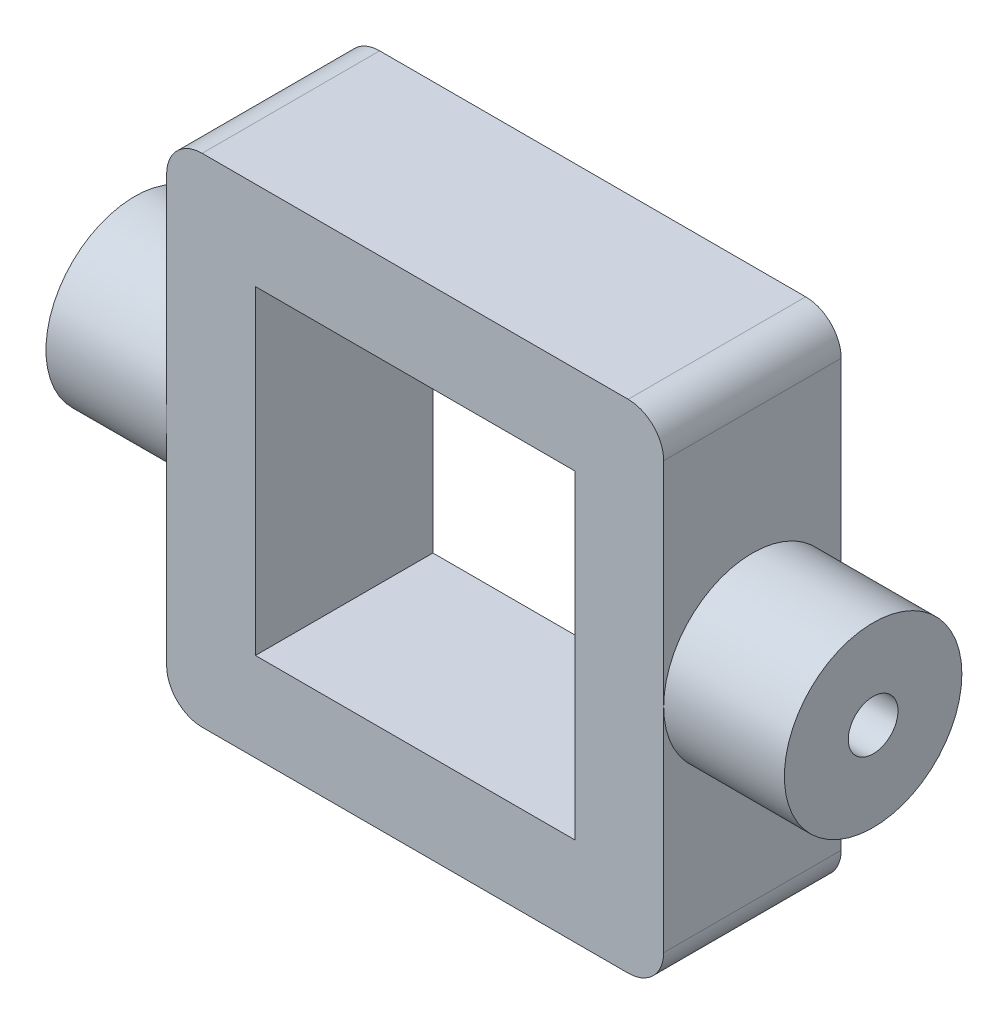
from build123d import *

# Parameters (mm, degrees)
SKETCH1_W           = 14
SKETCH1_H           = 14
SKETCH1_W_2         = 9
SKETCH1_H_2         = 9
BOSS_EXTRUDE1_DEPTH = 2.5
SKETCH3_R           = 2.5
BOSS_EXTRUDE2_DEPTH = 3.4
SKETCH4_R           = 0.7
CUT_EXTRUDE1_DEPTH  = 5
FILLET1_R           = 1


with BuildPart() as part:
    # Sketch1 → Boss-Extrude1 (new body, symmetric)
    with BuildSketch(Plane.XY):
        Rectangle(SKETCH1_W, SKETCH1_H)
        Rectangle(SKETCH1_W_2, SKETCH1_H_2, mode=Mode.SUBTRACT)
    extrude(amount=BOSS_EXTRUDE1_DEPTH, both=True)

    # Sketch3 → Boss-Extrude2 (add)
    with BuildSketch(Plane(origin=(7, 0, 0), x_dir=(0, 0, -1), z_dir=(1, 0, 0))):
        Circle(SKETCH3_R)
    boss_extrude2 = extrude(amount=BOSS_EXTRUDE2_DEPTH)

    # Sketch4 → Cut-Extrude1 (cut)
    with BuildSketch(Plane(origin=(10.4, 0, 0), x_dir=(0, 0, -1), z_dir=(1, 0, 0))):
        Circle(SKETCH4_R)
    cut_extrude1 = extrude(amount=-CUT_EXTRUDE1_DEPTH, mode=Mode.SUBTRACT)

    # Mirror1: Boss-Extrude2, Cut-Extrude1 across plane
    add(boss_extrude2.mirror(Plane(origin=(0, 0, 0), x_dir=(0, 0, 1), z_dir=(1, 0, 0))))
    add(cut_extrude1.mirror(Plane(origin=(0, 0, 0), x_dir=(0, 0, 1), z_dir=(1, 0, 0))), mode=Mode.SUBTRACT)

    # Fillet1
    fillet1_edges = [part.edges().sort_by_distance(p)[0] for p in [
        (-7, 7, 0),
        (7, 7, 0),
        (7, -7, 0),
        (-7, -7, 0),
    ]]
    fillet(fillet1_edges, radius=FILLET1_R)


solid = part.part
